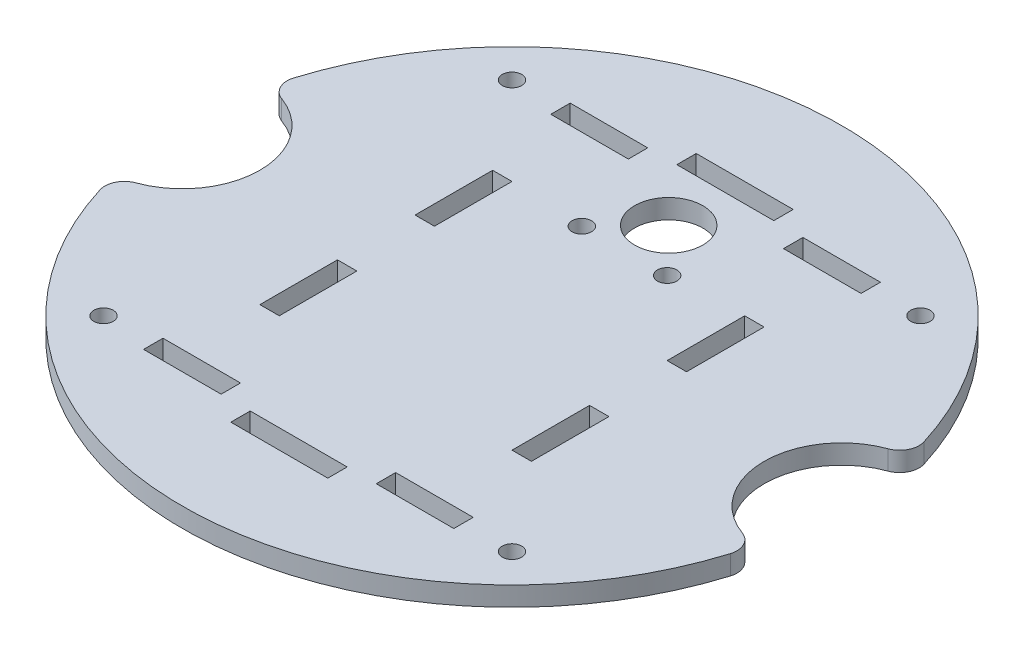
from build123d import *

# Parameters (mm, degrees)
SKETCH1_R           = 11.176
SKETCH1_R_2         = 3.175
SKETCH1_W           = 25.4
SKETCH1_H           = 6.35
SKETCH1_W_2         = 6.35
SKETCH1_H_2         = 25.4
SKETCH1_W_3         = 31.75
BOSS_EXTRUDE1_DEPTH = 6.35
SKETCH2_R           = 3.175
CUT_EXTRUDE1_DEPTH  = 6.35


with BuildPart() as part:
    # Sketch1 → Boss-Extrude1 (new body)
    with BuildSketch(Plane(origin=(0, 0, 0), x_dir=(1, 0, 0), z_dir=(0, 1, 0))):
        with BuildLine():
            ThreePointArc((-103.1875, -31.710287664), (0, -107.95), (103.1875, -31.710287664))
            ThreePointArc((103.1875, -31.710287664), (102.801250262, -27.013165433), (99.284117647, -23.8759813))
            ThreePointArc((99.284117647, -23.8759813), (82.55, 0), (99.284117647, 23.8759813))
            ThreePointArc((99.284117647, 23.8759813), (102.801250262, 27.013165433), (103.1875, 31.710287664))
            ThreePointArc((103.1875, 31.710287664), (0, 107.95), (-103.1875, 31.710287664))
            ThreePointArc((-103.1875, 31.710287664), (-102.801250262, 27.013165433), (-99.284117647, 23.8759813))
            ThreePointArc((-99.284117647, 23.8759813), (-82.55, 0), (-99.284117647, -23.8759813))
            ThreePointArc((-99.284117647, -23.8759813), (-102.801250262, -27.013165433), (-103.1875, -31.710287664))
        make_face()
        with Locations((0, 51.308)):
            Circle(SKETCH1_R, mode=Mode.SUBTRACT)
        with Locations((13.97, 36.83)):
            Circle(SKETCH1_R_2, mode=Mode.SUBTRACT)
        with Locations((-13.97, 36.83)):
            Circle(SKETCH1_R_2, mode=Mode.SUBTRACT)
        with Locations((-38.1, 66.675)):
            Rectangle(SKETCH1_W, SKETCH1_H, mode=Mode.SUBTRACT)
        with Locations((38.1, 66.675)):
            Rectangle(SKETCH1_W, SKETCH1_H, mode=Mode.SUBTRACT)
        with Locations((-38.1, -66.675)):
            Rectangle(SKETCH1_W, SKETCH1_H, mode=Mode.SUBTRACT)
        with Locations((38.1, -66.675)):
            Rectangle(SKETCH1_W, SKETCH1_H, mode=Mode.SUBTRACT)
        with Locations((41.275, -25.4)):
            Rectangle(SKETCH1_W_2, SKETCH1_H_2, mode=Mode.SUBTRACT)
        with Locations((41.275, 25.4)):
            Rectangle(SKETCH1_W_2, SKETCH1_H_2, mode=Mode.SUBTRACT)
        with Locations((-41.275, -25.4)):
            Rectangle(SKETCH1_W_2, SKETCH1_H_2, mode=Mode.SUBTRACT)
        with Locations((-41.275, 25.4)):
            Rectangle(SKETCH1_W_2, SKETCH1_H_2, mode=Mode.SUBTRACT)
        with Locations((0, 73.025)):
            Rectangle(SKETCH1_W_3, SKETCH1_H, mode=Mode.SUBTRACT)
        with Locations((0, -73.025)):
            Rectangle(SKETCH1_W_3, SKETCH1_H, mode=Mode.SUBTRACT)
    extrude(amount=BOSS_EXTRUDE1_DEPTH)

    # Sketch2 → Cut-Extrude1 (cut)
    with BuildSketch(Plane.XZ):
        with Locations((-66.8782, 66.8782)):
            Circle(SKETCH2_R)
        with Locations((66.8782, 66.8782)):
            Circle(SKETCH2_R)
        with Locations((66.8782, -66.8782)):
            Circle(SKETCH2_R)
        with Locations((-66.8782, -66.8782)):
            Circle(SKETCH2_R)
    extrude(amount=-CUT_EXTRUDE1_DEPTH, mode=Mode.SUBTRACT)


solid = part.part
